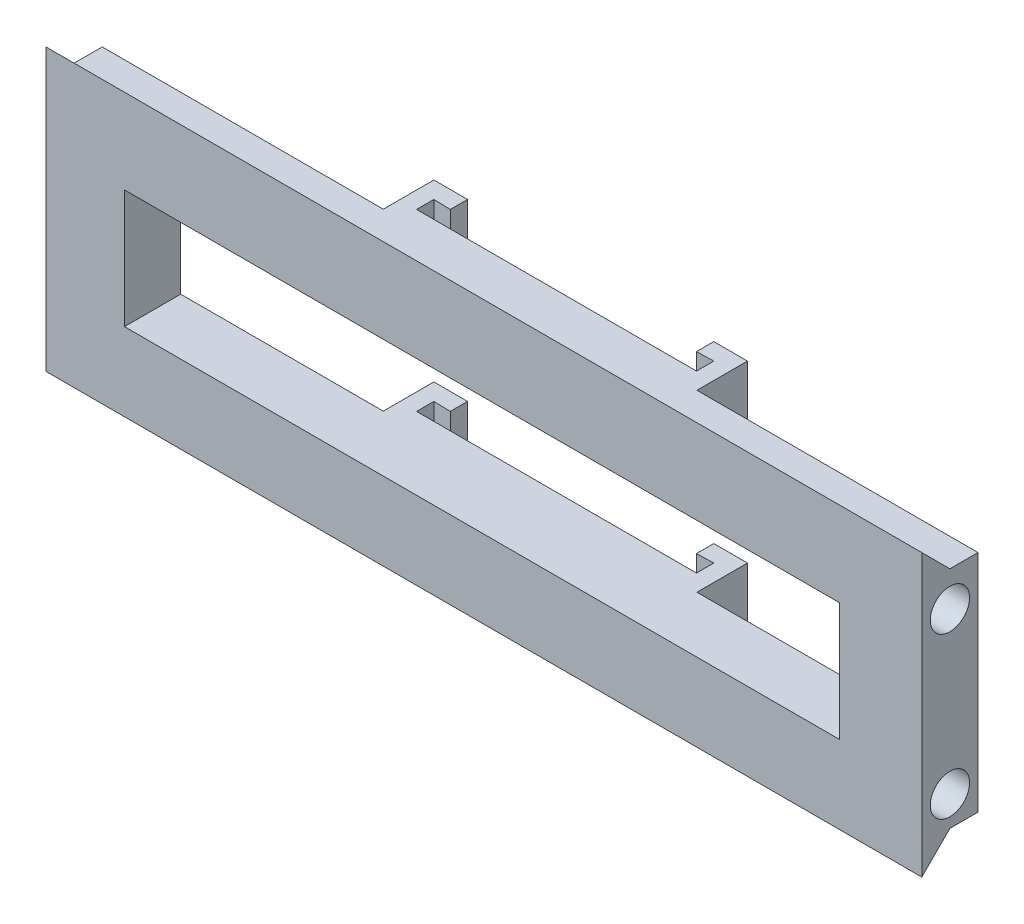
from build123d import *

# Parameters (mm, degrees)
BOSS_EXTRUDE1_DEPTH = 40
SKETCH2_W           = 127.211228058
SKETCH2_H           = 21.064469041
CUT_EXTRUDE1_DEPTH  = 60
BOSS_EXTRUDE2_DEPTH = 155.8
SKETCH4_R           = 3.5
CUT_EXTRUDE2_DEPTH  = 150


with BuildPart() as part:
    # Sketch1 → Boss-Extrude1 (new body)
    with BuildSketch(Plane(origin=(0, 0, 0), x_dir=(1, 0, 0), z_dir=(0, 1, 0))):
        Polygon((-60.768130494, -10.644024468), (-63.768130494, -10.644024468), (-63.768130494, -19.644024468), (-113.768130494, -19.644024468), (-113.768130494, -29.644024468), (42.031869506, -29.644024468), (42.031869506, -19.644024468), (-7.968130494, -19.644024468), (-7.968130494, -10.644024468), (-10.968130494, -10.644024468), (-13.968130494, -10.644024468), (-13.968130494, -13.726650188), (-10.968130494, -13.644024468), (-10.968130494, -16.726650188), (-13.968130494, -16.726650188), (-57.768130494, -16.726650188), (-60.768130494, -16.726650188), (-60.768130494, -13.644024468), (-57.768130494, -13.726650188), (-57.768130494, -10.644024468), align=None)
    extrude(amount=BOSS_EXTRUDE1_DEPTH)

    # Sketch2 → Cut-Extrude1 (cut)
    with BuildSketch(Plane.XY.offset(29.644024468)):
        with Locations((-36.201542798, 19.418495801)):
            Rectangle(SKETCH2_W, SKETCH2_H)
    extrude(amount=-CUT_EXTRUDE1_DEPTH, mode=Mode.SUBTRACT)

    # Sketch3 → Boss-Extrude2 (add)
    with BuildSketch(Plane(origin=(42.031869506, 0, 0), x_dir=(0, 0, -1), z_dir=(1, 0, 0))):
        Polygon((-29.644024468, 40), (-24.644024468, 40), (-29.644024468, 45), align=None)
        Polygon((-29.644024468, 0), (-29.644024468, -5), (-24.644024468, 0), align=None)
    extrude(amount=-BOSS_EXTRUDE2_DEPTH)

    # Sketch4 → Cut-Extrude2 (cut)
    with BuildSketch(Plane(origin=(42.031869506, 0, 0), x_dir=(0, 0, -1), z_dir=(1, 0, 0))):
        with Locations((-24.644024468, 33.806203399)):
            Circle(SKETCH4_R)
        with Locations((-24.644024468, 5.303574021)):
            Circle(SKETCH4_R)
    extrude(amount=-CUT_EXTRUDE2_DEPTH, mode=Mode.SUBTRACT)


solid = part.part
